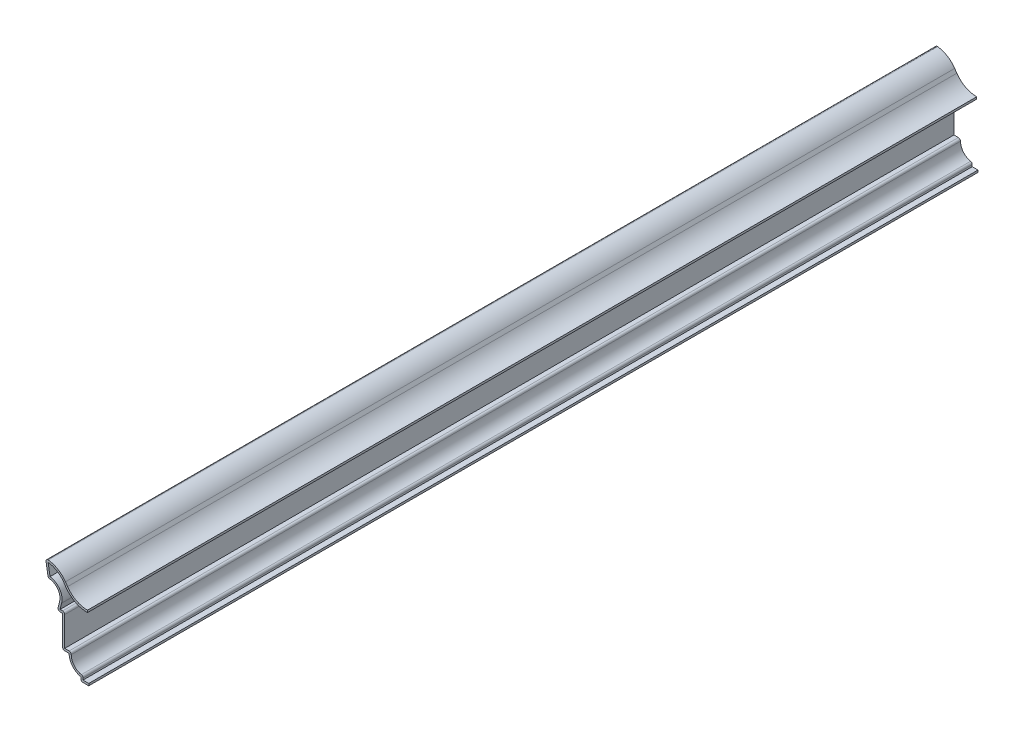
from build123d import *

# Parameters (mm, degrees)
EXTRUDE_THIN1_DEPTH = 539.75
FILLET1_R           = 1.27


with BuildPart() as part:
    # Sketch1 → Extrude-Thin1 (new body)
    with BuildSketch(Plane.XY):
        with BuildLine():
            Line((0, 0), (-4.7625, 0))
            Line((-4.7625, 0), (-4.7625, 2.38125))
            ThreePointArc((-4.7625, 2.38125), (-9.892743248, 5.471846434), (-11.90625, 11.1125))
            Line((-11.90625, 11.1125), (-15.875, 11.1125))
            Line((-15.875, 11.1125), (-15.875, 30.1625))
            Line((-15.875, 30.1625), (-19.05, 30.1625))
            Line((-19.05, 30.1625), (-17.682307692, 35.547788462))
            ThreePointArc((-17.682307692, 35.547788462), (-18.967315097, 41.692088258), (-24.60625, 44.45))
            Line((-24.60625, 44.45), (-26.19375, 53.975))
            ThreePointArc((-26.19375, 53.975), (-19.37999398, 52.288155979), (-14.140184362, 47.617277151))
            Line((-14.140184362, 47.617277151), (-12.847315638, 45.727722849))
            ThreePointArc((-12.847315638, 45.727722849), (-7.60750602, 41.056844021), (-0.79375, 39.37))
            Line((-0.79375, 39.37), (-0.79375, 38.1))
            ThreePointArc((-0.79375, 38.1), (-8.200006544, 39.93352611), (-13.89545178, 45.010568314))
            Line((-13.89545178, 45.010568314), (-15.188320504, 46.900122616))
            ThreePointArc((-15.188320504, 46.900122616), (-19.312101481, 50.792133717), (-24.680202995, 52.618826381))
            Line((-24.680202995, 52.618826381), (-23.518633198, 45.649407601))
            ThreePointArc((-23.518633198, 45.649407601), (-17.64421442, 42.030786976), (-16.451384615, 35.235173077))
            Line((-16.451384615, 35.235173077), (-17.417142857, 31.4325))
            Line((-17.417142857, 31.4325), (-14.605, 31.4325))
            Line((-14.605, 31.4325), (-14.605, 12.3825))
            Line((-14.605, 12.3825), (-10.529920944, 12.3825))
            ThreePointArc((-10.529920944, 12.3825), (-8.987461499, 6.372542318), (-3.4925, 3.490846534))
            Line((-3.4925, 3.490846534), (-3.4925, 1.27))
            Line((-3.4925, 1.27), (0, 1.27))
            Line((0, 1.27), (0, 0))
        make_face()
    extrude(amount=-EXTRUDE_THIN1_DEPTH)

    # Fillet1
    fillet1_edges = [part.edges().sort_by_distance(p)[0] for p in [
        (-14.605, 31.4325, -269.875),
        (-10.529920944, 12.3825, -269.875),
        (-3.4925, 3.490846534, -269.875),
        (-4.7625, 0, -269.875),
        (-15.875, 11.1125, -269.875),
        (-19.05, 30.1625, -269.875),
        (-24.60625, 44.45, -269.875),
        (-26.19375, 53.975, -269.875),
    ]]
    fillet(fillet1_edges, radius=FILLET1_R)


solid = part.part
